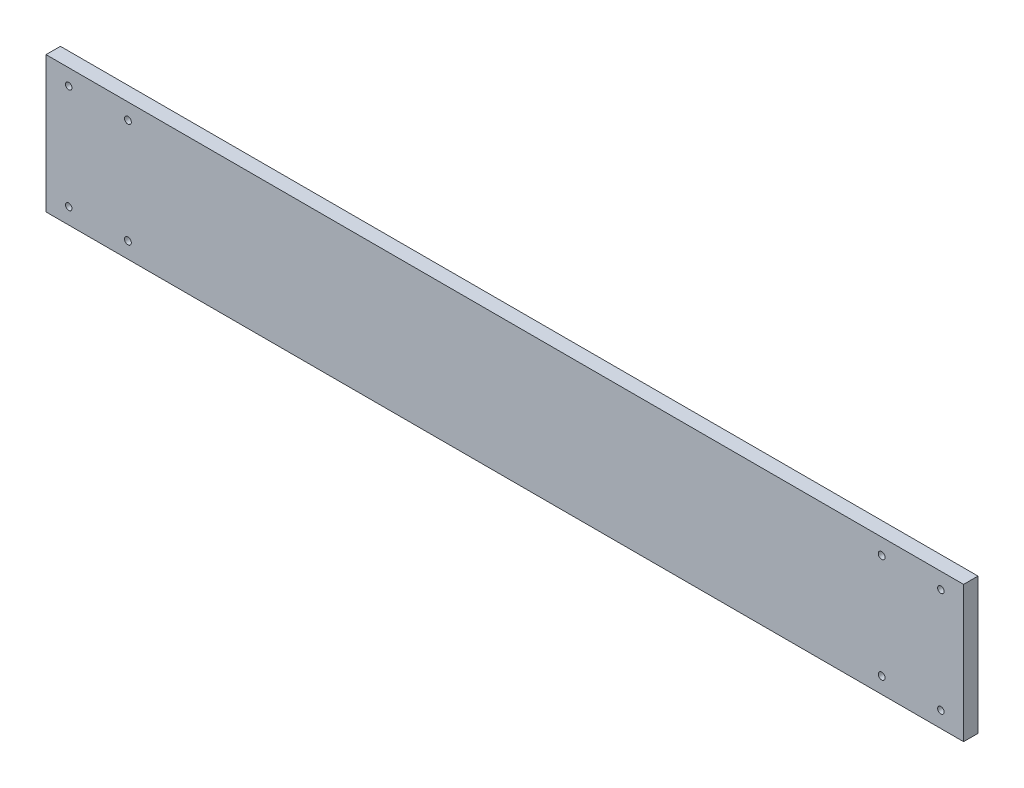
from build123d import *

# Parameters (mm, degrees)
SKETCH1_W           = 404.0501952
SKETCH1_H           = 60
BOSS_EXTRUDE1_DEPTH = 6.35
SKETCH3_R           = 1.5
SKETCH3_R_2         = 1.425
CUT_EXTRUDE1_DEPTH  = 7.35


with BuildPart() as part:
    # Sketch1 → Boss-Extrude1 (new body)
    with BuildSketch(Plane.XY):
        with Locations((0, 48.148481108)):
            Rectangle(SKETCH1_W, SKETCH1_H)
    extrude(amount=BOSS_EXTRUDE1_DEPTH)

    # Sketch3 → Cut-Extrude1 (cut, through all)
    with BuildSketch(Plane.XY.offset(6.35)):
        with Locations((-165.950402598, 25.148481108)):
            Circle(SKETCH3_R)
        with Locations((-165.950402598, 71.148481108)):
            Circle(SKETCH3_R)
        with Locations((165.950402598, 25.148481108)):
            Circle(SKETCH3_R)
        with Locations((165.950402598, 71.148481108)):
            Circle(SKETCH3_R)
        with Locations((192.0250976, 71.148481108)):
            Circle(SKETCH3_R_2)
        with Locations((192.0250976, 25.148481108)):
            Circle(SKETCH3_R_2)
        with Locations((-192.0250976, 25.148481108)):
            Circle(SKETCH3_R_2)
        with Locations((-192.0250976, 71.148481108)):
            Circle(SKETCH3_R_2)
    extrude(amount=-CUT_EXTRUDE1_DEPTH, mode=Mode.SUBTRACT)


solid = part.part
